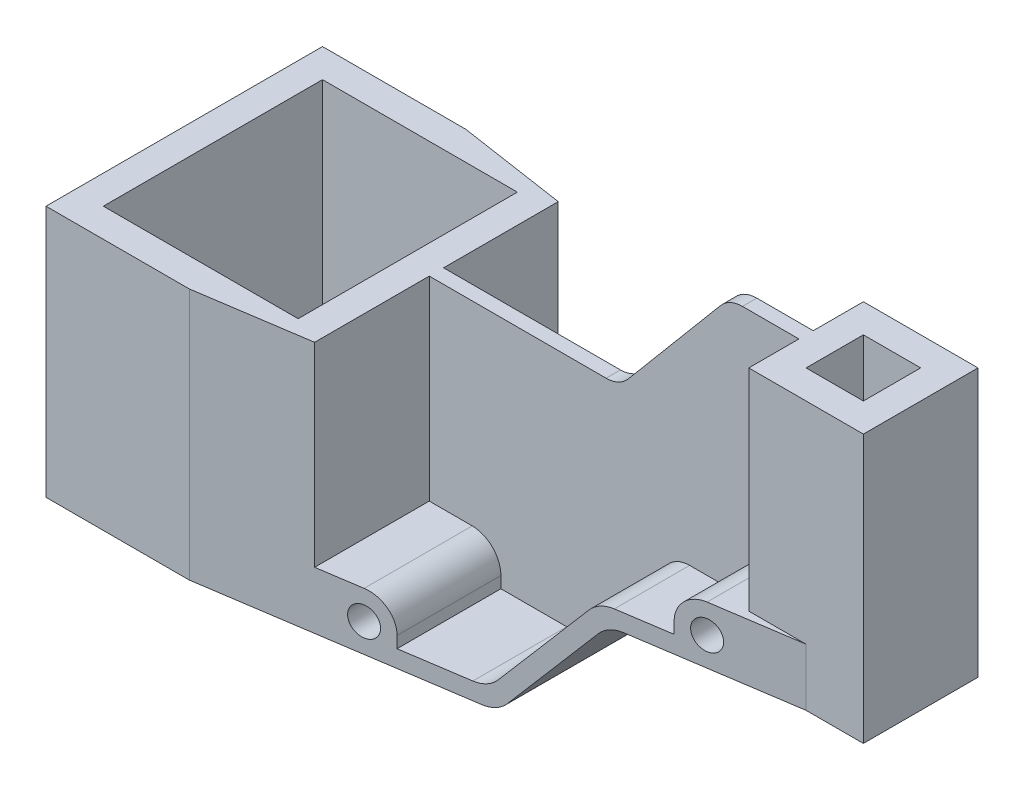
from build123d import *

# Parameters (mm, degrees)
SKETCH1_W           = 257
SKETCH1_H           = 133.5
BOSS_EXTRUDE1_DEPTH = 96.5
SKETCH2_W           = 113
SKETCH2_H           = 45.5
SKETCH2_W_2         = 80
SKETCH2_H_2         = 40
CUT_EXTRUDE1_DEPTH  = 96.5
CUT_EXTRUDE2_DEPTH  = 88
SKETCH6_W           = 20
SKETCH6_H           = 28.25
CUT_EXTRUDE3_DEPTH  = 93.5
SKETCH7_W           = 124
SKETCH7_H           = 28.25
CUT_EXTRUDE4_DEPTH  = 73.5
SKETCH8_W           = 104
SKETCH8_H           = 17.5
CUT_EXTRUDE5_DEPTH  = 73.5
SKETCH9_W           = 25
SKETCH9_H           = 45.75
CUT_EXTRUDE6_DEPTH  = 68
SKETCH11_W          = 84
SKETCH11_H          = 45.75
CUT_EXTRUDE7_DEPTH  = 14
SKETCH12_W          = 84
SKETCH12_H          = 45.75
CUT_EXTRUDE8_DEPTH  = 14
CUT_EXTRUDE10_DEPTH = 45.75
CUT_EXTRUDE11_DEPTH = 96.5
CUT_EXTRUDE12_DEPTH = 45.75
CUT_EXTRUDE13_DEPTH = 5
SKETCH18_R          = 5
CUT_EXTRUDE14_DEPTH = 96.5
SKETCH19_W          = 20
SKETCH19_H          = 20
CUT_EXTRUDE15_DEPTH = 93.5
CUT_EXTRUDE42_DEPTH = 88
CUT_EXTRUDE53_DEPTH = 20
CUT_EXTRUDE61_DEPTH = 50.68
CUT_EXTRUDE62_DEPTH = 88
CUT_EXTRUDE63_DEPTH = 88
CUT_EXTRUDE64_DEPTH = 88
FILLET2_R           = 10
FILLET3_R           = 10
FILLET4_R           = 10
FILLET5_R           = 10
FILLET6_R           = 10
FILLET7_R           = 10
FILLET8_R           = 10
FILLET9_R           = 10
FILLET10_R          = 10
FILLET11_R          = 10
FILLET12_R          = 10
FILLET13_R          = 10


with BuildPart() as part:
    # Sketch1 → Boss-Extrude1 (new body)
    with BuildSketch(Plane.XY):
        with Locations((93.989304803, 40.957796221)):
            Rectangle(SKETCH1_W, SKETCH1_H)
    extrude(amount=BOSS_EXTRUDE1_DEPTH)

    # Sketch2 → Cut-Extrude1 (cut)
    with BuildSketch(Plane.XY.offset(96.5)):
        with Locations((21.989304803, 84.957796221)):
            Rectangle(SKETCH2_W, SKETCH2_H)
        with Locations((182.489304803, -5.792203779)):
            Rectangle(SKETCH2_W_2, SKETCH2_H_2)
    extrude(amount=-CUT_EXTRUDE1_DEPTH, mode=Mode.SUBTRACT)

    # Sketch4 → Cut-Extrude2 (cut)
    with BuildSketch(Plane(origin=(0, 62.207796221, 0), x_dir=(1, 0, 0), z_dir=(0, 1, 0))):
        Polygon((-24.510695197, -10), (-24.510695197, -48.25), (-24.510695197, -86.5), (43.489304803, -86.5), (43.489304803, -48.25), (43.489304803, -10), align=None)
    extrude(amount=-CUT_EXTRUDE2_DEPTH, mode=Mode.SUBTRACT)

    # Sketch6 → Cut-Extrude3 (cut)
    with BuildSketch(Plane(origin=(0, 107.707796221, 0), x_dir=(1, 0, 0), z_dir=(0, 1, 0))):
        with Locations((212.489304803, -14.125)):
            Rectangle(SKETCH6_W, SKETCH6_H)
        with Locations((212.489304803, -82.375)):
            Rectangle(SKETCH6_W, SKETCH6_H)
    extrude(amount=-CUT_EXTRUDE3_DEPTH, mode=Mode.SUBTRACT)

    # Sketch7 → Cut-Extrude4 (cut)
    with BuildSketch(Plane(origin=(0, 107.707796221, 0), x_dir=(1, 0, 0), z_dir=(0, 1, 0))):
        with Locations((140.489304803, -14.125)):
            Rectangle(SKETCH7_W, SKETCH7_H)
        with Locations((140.489304803, -82.375)):
            Rectangle(SKETCH7_W, SKETCH7_H)
    extrude(amount=-CUT_EXTRUDE4_DEPTH, mode=Mode.SUBTRACT)

    # Sketch8 → Cut-Extrude5 (cut)
    with BuildSketch(Plane(origin=(0, 107.707796221, 0), x_dir=(1, 0, 0), z_dir=(0, 1, 0))):
        with Locations((130.489304803, -37)):
            Rectangle(SKETCH8_W, SKETCH8_H)
        with Locations((130.489304803, -59.5)):
            Rectangle(SKETCH8_W, SKETCH8_H)
    extrude(amount=-CUT_EXTRUDE5_DEPTH, mode=Mode.SUBTRACT)

    # Sketch9 → Cut-Extrude6 (cut)
    with BuildSketch(Plane(origin=(0, 62.207796221, 0), x_dir=(1, 0, 0), z_dir=(0, 1, 0))):
        with Locations((65.989304803, -73.625)):
            Rectangle(SKETCH9_W, SKETCH9_H)
        with Locations((65.989304803, -22.875)):
            Rectangle(SKETCH9_W, SKETCH9_H)
    extrude(amount=-CUT_EXTRUDE6_DEPTH, mode=Mode.SUBTRACT)

    # Sketch11 → Cut-Extrude7 (cut)
    with BuildSketch(Plane(origin=(0, 34.207796221, 0), x_dir=(1, 0, 0), z_dir=(0, 1, 0))):
        with Locations((120.489304803, -73.625)):
            Rectangle(SKETCH11_W, SKETCH11_H)
    extrude(amount=-CUT_EXTRUDE7_DEPTH, mode=Mode.SUBTRACT)

    # Sketch12 → Cut-Extrude8 (cut)
    with BuildSketch(Plane(origin=(0, 34.207796221, 0), x_dir=(1, 0, 0), z_dir=(0, 1, 0))):
        with Locations((120.489304803, -22.875)):
            Rectangle(SKETCH12_W, SKETCH12_H)
    extrude(amount=-CUT_EXTRUDE8_DEPTH, mode=Mode.SUBTRACT)

    # Sketch13 → Cut-Extrude10 (cut)
    with BuildSketch(Plane.XY.offset(96.5)):
        Polygon((139.691458854, 20.207796221), (106.127473607, -19.792203779), (78.489304803, -19.792203779), (78.489304803, 20.207796221), align=None)
    extrude(amount=-CUT_EXTRUDE10_DEPTH, mode=Mode.SUBTRACT)

    # Sketch15 → Cut-Extrude11 (cut)
    with BuildSketch(Plane.XY.offset(96.5)):
        Polygon((142.489304803, 14.207796221), (108.925319556, -25.792203779), (142.489304803, -25.792203779), align=None)
    extrude(amount=-CUT_EXTRUDE11_DEPTH, mode=Mode.SUBTRACT)

    # Sketch16 → Cut-Extrude12 (cut)
    with BuildSketch(Plane(origin=(0, 0, 0), x_dir=(-1, 0, 0), z_dir=(0, 0, -1))):
        Polygon((-78.489304803, -19.792203779), (-106.127473607, -19.792203779), (-139.691458854, 20.207796221), (-78.489304803, 20.207796221), align=None)
    extrude(amount=-CUT_EXTRUDE12_DEPTH, mode=Mode.SUBTRACT)

    # Sketch17 → Cut-Extrude13 (cut)
    with BuildSketch(Plane.XY.offset(50.75)):
        Polygon((78.489304803, 62.207796221), (119.862118509, 62.207796221), (158.148215693, 107.707796221), (78.489304803, 107.707796221), align=None)
    extrude(amount=-CUT_EXTRUDE13_DEPTH, mode=Mode.SUBTRACT)

    # Sketch18 → Cut-Extrude14 (cut)
    with BuildSketch(Plane.XY.offset(96.5)):
        with Locations((172.489304803, 24.207796221)):
            Circle(SKETCH18_R)
        with Locations((68.489304803, -15.792203779)):
            Circle(SKETCH18_R)
    extrude(amount=-CUT_EXTRUDE14_DEPTH, mode=Mode.SUBTRACT)

    # Sketch19 → Cut-Extrude15 (cut)
    with BuildSketch(Plane(origin=(0, 107.707796221, 0), x_dir=(1, 0, 0), z_dir=(0, 1, 0))):
        with Locations((202.489304803, -48.25)):
            Rectangle(SKETCH19_W, SKETCH19_H)
    extrude(amount=-CUT_EXTRUDE15_DEPTH, mode=Mode.SUBTRACT)

    # Sketch51 → Cut-Extrude42 (cut)
    with BuildSketch(Plane(origin=(0, 62.207796221, 0), x_dir=(1, 0, 0), z_dir=(0, 1, 0))):
        Polygon((15.489304803, -96.5), (53.489304803, -96.5), (53.489304803, -90.759358289), align=None)
    extrude(amount=-CUT_EXTRUDE42_DEPTH, mode=Mode.SUBTRACT)

    # Sketch62 → Cut-Extrude53 (cut)
    with BuildSketch(Plane.XZ.offset(-14.207796221)):
        Polygon((142.489304803, 96.5), (202.489304803, 96.5), (202.489304803, 68.25), (142.489304803, 77.314171123), align=None)
    extrude(amount=-CUT_EXTRUDE53_DEPTH, mode=Mode.SUBTRACT)

    # Sketch75 → Cut-Extrude61 (cut)
    with BuildSketch(Plane.XZ.offset(25.792203779)):
        Polygon((142.489304803, 77.314171123), (53.489304803, 90.759358289), (53.489304803, 96.5), (142.489304803, 96.5), align=None)
    extrude(amount=-CUT_EXTRUDE61_DEPTH, mode=Mode.SUBTRACT)

    # Sketch79 → Cut-Extrude62 (cut)
    with BuildSketch(Plane(origin=(0, 62.207796221, 0), x_dir=(1, 0, 0), z_dir=(0, 1, 0))):
        Polygon((15.489304803, 0), (53.489304803, 0), (53.489304803, -5.740641711), align=None)
    extrude(amount=-CUT_EXTRUDE62_DEPTH, mode=Mode.SUBTRACT)

    # Sketch80 → Cut-Extrude63 (cut)
    with BuildSketch(Plane.XZ.offset(25.792203779)):
        Polygon((53.489304803, 5.740641711), (53.489304803, 0), (142.489304803, 0), (142.489304803, 19.185828877), align=None)
    extrude(amount=-CUT_EXTRUDE63_DEPTH, mode=Mode.SUBTRACT)

    # Sketch81 → Cut-Extrude64 (cut)
    with BuildSketch(Plane.XZ.offset(-14.207796221)):
        Polygon((142.489304803, 19.185828877), (202.489304803, 28.25), (202.489304803, 0), (142.489304803, 0), align=None)
    extrude(amount=-CUT_EXTRUDE64_DEPTH, mode=Mode.SUBTRACT)

    # Fillet2
    fillet2_edges = [part.edges().sort_by_distance(p)[0] for p in [
        (162.489304803, 34.207796221, 62.521390374),
    ]]
    fillet(fillet2_edges, radius=FILLET2_R)

    # Fillet3
    fillet3_edges = [part.edges().sort_by_distance(p)[0] for p in [
        (162.489304803, 34.207796221, 33.978609626),
    ]]
    fillet(fillet3_edges, radius=FILLET3_R)

    # Fillet4
    fillet4_edges = [part.edges().sort_by_distance(p)[0] for p in [
        (139.691458854, 20.207796221, 32.256579818),
    ]]
    fillet(fillet4_edges, radius=FILLET4_R)

    # Fillet5
    fillet5_edges = [part.edges().sort_by_distance(p)[0] for p in [
        (139.691458854, 20.207796221, 64.243420182),
    ]]
    fillet(fillet5_edges, radius=FILLET5_R)

    # Fillet6
    fillet6_edges = [part.edges().sort_by_distance(p)[0] for p in [
        (106.127473607, -19.792203779, 66.778667731),
    ]]
    fillet(fillet6_edges, radius=FILLET6_R)

    # Fillet7
    fillet7_edges = [part.edges().sort_by_distance(p)[0] for p in [
        (106.127473607, -19.792203779, 29.721332269),
    ]]
    fillet(fillet7_edges, radius=FILLET7_R)

    # Fillet8
    fillet8_edges = [part.edges().sort_by_distance(p)[0] for p in [
        (78.489304803, -5.792203779, 68.86631016),
    ]]
    fillet(fillet8_edges, radius=FILLET8_R)

    # Fillet9
    fillet9_edges = [part.edges().sort_by_distance(p)[0] for p in [
        (78.489304803, -5.792203779, 27.63368984),
    ]]
    fillet(fillet9_edges, radius=FILLET9_R)

    # Fillet10
    fillet10_edges = [part.edges().sort_by_distance(p)[0] for p in [
        (158.148215693, 107.707796221, 48.25),
    ]]
    fillet(fillet10_edges, radius=FILLET10_R)

    # Fillet11
    fillet11_edges = [part.edges().sort_by_distance(p)[0] for p in [
        (119.862118509, 62.207796221, 48.25),
    ]]
    fillet(fillet11_edges, radius=FILLET11_R)

    # Fillet12
    fillet12_edges = [part.edges().sort_by_distance(p)[0] for p in [
        (142.489304803, 14.207796221, 48.25),
    ]]
    fillet(fillet12_edges, radius=FILLET12_R)

    # Fillet13
    fillet13_edges = [part.edges().sort_by_distance(p)[0] for p in [
        (108.925319556, -25.792203779, 48.25),
    ]]
    fillet(fillet13_edges, radius=FILLET13_R)


solid = part.part
